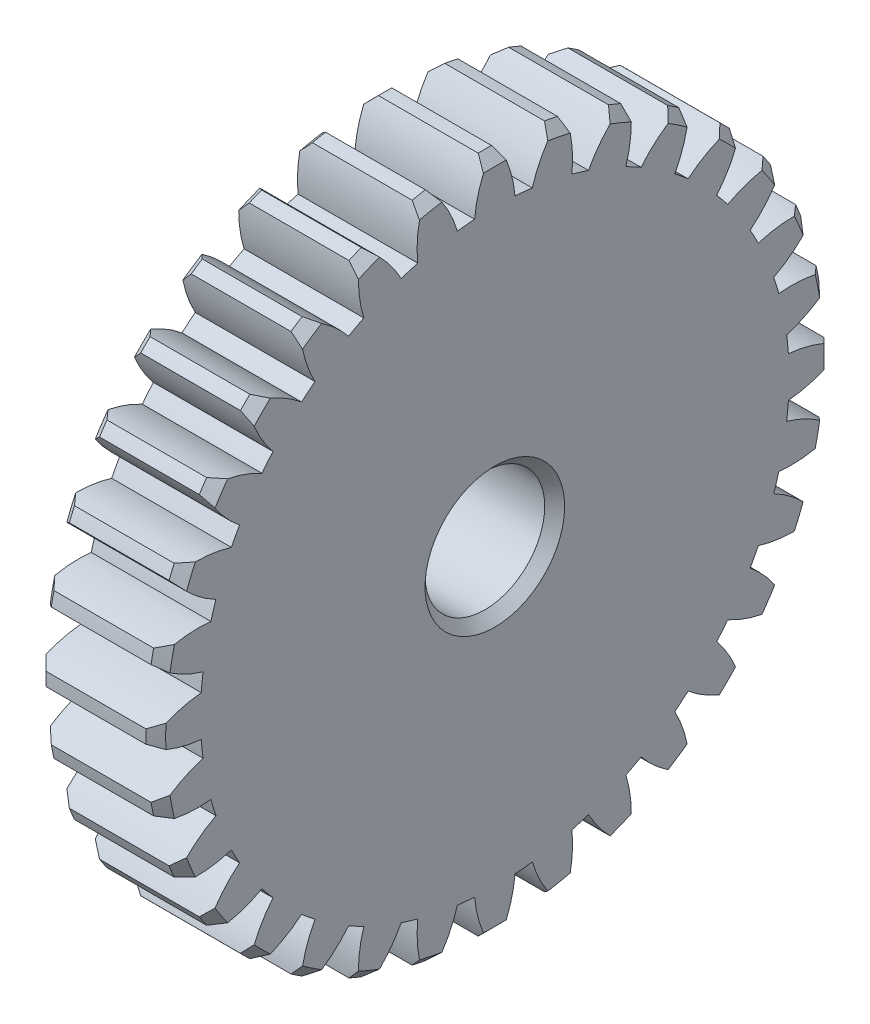
from build123d import *

# Parameters (mm, degrees)
SKETCH1_W                    = 6
SKETCH1_H                    = 17
CUT_EXTRUDE1_DEPTH           = 7
CUT_EXTRUDE2_DEPTH           = 7
CUT_EXTRUDE3_DEPTH           = 7
CUT_EXTRUDE4_DEPTH           = 7
CUT_EXTRUDE5_DEPTH           = 7
CUT_EXTRUDE6_DEPTH           = 7
CUT_EXTRUDE7_DEPTH           = 7
CUT_EXTRUDE8_DEPTH           = 7
CUT_EXTRUDE9_DEPTH           = 7
CUT_EXTRUDE10_DEPTH          = 7
CUT_EXTRUDE11_DEPTH          = 7
CUT_EXTRUDE12_DEPTH          = 7
CUT_EXTRUDE13_DEPTH          = 7
CUT_EXTRUDE14_DEPTH          = 7
CUT_EXTRUDE15_DEPTH          = 7
CUT_EXTRUDE16_DEPTH          = 7
CUT_EXTRUDE17_DEPTH          = 7
CUT_EXTRUDE18_DEPTH          = 7
CUT_EXTRUDE19_DEPTH          = 7
CUT_EXTRUDE20_DEPTH          = 7
CUT_EXTRUDE21_DEPTH          = 7
CUT_EXTRUDE22_DEPTH          = 7
CUT_EXTRUDE23_DEPTH          = 7
CUT_EXTRUDE24_DEPTH          = 7
CUT_EXTRUDE25_DEPTH          = 7
CUT_EXTRUDE26_DEPTH          = 7
CUT_EXTRUDE27_DEPTH          = 7
CUT_EXTRUDE28_DEPTH          = 7
CUT_EXTRUDE29_DEPTH          = 7
CUT_EXTRUDE30_DEPTH          = 7
CUT_EXTRUDE31_DEPTH          = 7
CUT_EXTRUDE32_DEPTH          = 7
F_6_0_6_DIAMETER_HOLE1_D     = 6
F_6_0_6_DIAMETER_HOLE1_DEPTH = 6
CHAMFER1_SIZE                = 0.5


with BuildPart() as part:
    # Sketch1 → Revolve1 (revolve)
    with BuildSketch(Plane.XY):
        with Locations((3, 8.5)):
            Rectangle(SKETCH1_W, SKETCH1_H)
    revolve(axis=Axis((0, 0, 0), (1, 0, 0)))

    # Sketch2 → Cut-Extrude1 (cut, through all)
    with BuildSketch(Plane(origin=(6, 0, 0), x_dir=(0, 0, -1), z_dir=(1, 0, 0))):
        with BuildLine():
            ThreePointArc((2.988536759, 16.735251658), (1.666291386, 16.918140353), (0.333772772, 16.996723088))
            ThreePointArc((0.333772772, 16.996723088), (0.787598479, 15.889968944), (1.012856819, 14.715183351))
            ThreePointArc((1.012856819, 14.715183351), (1.44575282, 14.678974718), (1.8773948, 14.630033792))
            ThreePointArc((1.8773948, 14.630033792), (2.327514163, 15.738300487), (2.988536759, 16.735251658))
        make_face()
    extrude(amount=-CUT_EXTRUDE1_DEPTH, mode=Mode.SUBTRACT)

    # Sketch3 → Cut-Extrude2 (cut, through all)
    with BuildSketch(Plane(origin=(6, 0, 0), x_dir=(0, 0, -1), z_dir=(1, 0, 0))):
        with BuildLine():
            ThreePointArc((6.195998498, 15.830653891), (4.934839513, 16.267985707), (3.643255602, 16.605019982))
            ThreePointArc((3.643255602, 16.605019982), (3.872444154, 15.430994806), (3.864184917, 14.234836667))
            ThreePointArc((3.864184917, 14.234836667), (4.28169899, 14.114869952), (4.695499189, 13.982660239))
            ThreePointArc((4.695499189, 13.982660239), (5.353181741, 14.981817969), (6.195998498, 15.830653891))
        make_face()
    extrude(amount=-CUT_EXTRUDE2_DEPTH, mode=Mode.SUBTRACT)

    # Sketch4 → Cut-Extrude3 (cut, through all)
    with BuildSketch(Plane(origin=(6, 0, 0), x_dir=(0, 0, -1), z_dir=(1, 0, 0))):
        with BuildLine():
            ThreePointArc((9.165351489, 14.317692973), (8.013744526, 14.992661494), (6.812730163, 15.575195271))
            ThreePointArc((6.812730163, 15.575195271), (6.808473971, 14.37901619), (6.567014557, 13.207453192))
            ThreePointArc((6.567014557, 13.207453192), (6.953101868, 13.008338649), (7.333158177, 12.797940895))
            ThreePointArc((7.333158177, 12.797940895), (8.173129547, 13.649592588), (9.165351489, 14.317692973))
        make_face()
    extrude(amount=-CUT_EXTRUDE3_DEPTH, mode=Mode.SUBTRACT)

    # Sketch5 → Cut-Extrude4 (cut, through all)
    with BuildSketch(Plane(origin=(6, 0, 0), x_dir=(0, 0, -1), z_dir=(1, 0, 0))):
        with BuildLine():
            ThreePointArc((11.782485163, 12.254511144), (10.784685831, 13.141177707), (9.720395324, 13.94682454))
            ThreePointArc((9.720395324, 13.94682454), (9.482857951, 12.774460047), (9.01747751, 11.672514697))
            ThreePointArc((9.01747751, 11.672514697), (9.357300941, 11.401904187), (9.689008009, 11.121403859))
            ThreePointArc((9.689008009, 11.121403859), (10.678988568, 11.792821019), (11.782485163, 12.254511144))
        make_face()
    extrude(amount=-CUT_EXTRUDE4_DEPTH, mode=Mode.SUBTRACT)

    # Sketch6 → Cut-Extrude5 (cut, through all)
    with BuildSketch(Plane(origin=(6, 0, 0), x_dir=(0, 0, -1), z_dir=(1, 0, 0))):
        with BuildLine():
            ThreePointArc((13.94682454, 9.720395324), (13.141177707, 10.784685831), (12.254511144, 11.782485163))
            ThreePointArc((12.254511144, 11.782485163), (11.792821019, 10.678988568), (11.121403859, 9.689008009))
            ThreePointArc((11.121403859, 9.689008009), (11.401904187, 9.357300941), (11.672514697, 9.01747751))
            ThreePointArc((11.672514697, 9.01747751), (12.774460047, 9.482857951), (13.94682454, 9.720395324))
        make_face()
    extrude(amount=-CUT_EXTRUDE5_DEPTH, mode=Mode.SUBTRACT)

    # Sketch7 → Cut-Extrude6 (cut, through all)
    with BuildSketch(Plane(origin=(6, 0, 0), x_dir=(0, 0, -1), z_dir=(1, 0, 0))):
        with BuildLine():
            ThreePointArc((15.575195271, 6.812730163), (14.992661494, 8.013744526), (14.317692973, 9.165351489))
            ThreePointArc((14.317692973, 9.165351489), (13.649592588, 8.173129547), (12.797940895, 7.333158177))
            ThreePointArc((12.797940895, 7.333158177), (13.008338649, 6.953101868), (13.207453192, 6.567014557))
            ThreePointArc((13.207453192, 6.567014557), (14.37901619, 6.808473971), (15.575195271, 6.812730163))
        make_face()
    extrude(amount=-CUT_EXTRUDE6_DEPTH, mode=Mode.SUBTRACT)

    # Sketch8 → Cut-Extrude7 (cut, through all)
    with BuildSketch(Plane(origin=(6, 0, 0), x_dir=(0, 0, -1), z_dir=(1, 0, 0))):
        with BuildLine():
            ThreePointArc((16.605019982, 3.643255602), (16.267985707, 4.934839513), (15.830653891, 6.195998498))
            ThreePointArc((15.830653891, 6.195998498), (14.981817969, 5.353181741), (13.982660239, 4.695499189))
            ThreePointArc((13.982660239, 4.695499189), (14.114869952, 4.28169899), (14.234836667, 3.864184917))
            ThreePointArc((14.234836667, 3.864184917), (15.430994806, 3.872444154), (16.605019982, 3.643255602))
        make_face()
    extrude(amount=-CUT_EXTRUDE7_DEPTH, mode=Mode.SUBTRACT)

    # Sketch9 → Cut-Extrude8 (cut, through all)
    with BuildSketch(Plane(origin=(6, 0, 0), x_dir=(0, 0, -1), z_dir=(1, 0, 0))):
        with BuildLine():
            ThreePointArc((16.996723088, 0.333772772), (16.918140353, 1.666291386), (16.735251658, 2.988536759))
            ThreePointArc((16.735251658, 2.988536759), (15.738300487, 2.327514163), (14.630033792, 1.8773948))
            ThreePointArc((14.630033792, 1.8773948), (14.678974718, 1.44575282), (14.715183351, 1.012856819))
            ThreePointArc((14.715183351, 1.012856819), (15.889968944, 0.787598479), (16.996723088, 0.333772772))
        make_face()
    extrude(amount=-CUT_EXTRUDE8_DEPTH, mode=Mode.SUBTRACT)

    # Sketch10 → Cut-Extrude9 (cut, through all)
    with BuildSketch(Plane(origin=(6, 0, 0), x_dir=(0, 0, -1), z_dir=(1, 0, 0))):
        with BuildLine():
            ThreePointArc((16.735251658, -2.988536759), (16.918140353, -1.666291386), (16.996723088, -0.333772772))
            ThreePointArc((16.996723088, -0.333772772), (15.889968944, -0.787598479), (14.715183351, -1.012856819))
            ThreePointArc((14.715183351, -1.012856819), (14.678974718, -1.44575282), (14.630033792, -1.8773948))
            ThreePointArc((14.630033792, -1.8773948), (15.738300487, -2.327514163), (16.735251658, -2.988536759))
        make_face()
    extrude(amount=-CUT_EXTRUDE9_DEPTH, mode=Mode.SUBTRACT)

    # Sketch11 → Cut-Extrude10 (cut, through all)
    with BuildSketch(Plane(origin=(6, 0, 0), x_dir=(0, 0, -1), z_dir=(1, 0, 0))):
        with BuildLine():
            ThreePointArc((15.830653891, -6.195998498), (16.267985707, -4.934839513), (16.605019982, -3.643255602))
            ThreePointArc((16.605019982, -3.643255602), (15.430994806, -3.872444154), (14.234836667, -3.864184917))
            ThreePointArc((14.234836667, -3.864184917), (14.114869952, -4.28169899), (13.982660239, -4.695499189))
            ThreePointArc((13.982660239, -4.695499189), (14.981817969, -5.353181741), (15.830653891, -6.195998498))
        make_face()
    extrude(amount=-CUT_EXTRUDE10_DEPTH, mode=Mode.SUBTRACT)

    # Sketch12 → Cut-Extrude11 (cut, through all)
    with BuildSketch(Plane(origin=(6, 0, 0), x_dir=(0, 0, -1), z_dir=(1, 0, 0))):
        with BuildLine():
            ThreePointArc((14.317692973, -9.165351489), (14.992661494, -8.013744526), (15.575195271, -6.812730163))
            ThreePointArc((15.575195271, -6.812730163), (14.37901619, -6.808473971), (13.207453192, -6.567014557))
            ThreePointArc((13.207453192, -6.567014557), (13.008338649, -6.953101868), (12.797940895, -7.333158177))
            ThreePointArc((12.797940895, -7.333158177), (13.649592588, -8.173129547), (14.317692973, -9.165351489))
        make_face()
    extrude(amount=-CUT_EXTRUDE11_DEPTH, mode=Mode.SUBTRACT)

    # Sketch13 → Cut-Extrude12 (cut, through all)
    with BuildSketch(Plane(origin=(6, 0, 0), x_dir=(0, 0, -1), z_dir=(1, 0, 0))):
        with BuildLine():
            ThreePointArc((12.254511144, -11.782485163), (13.141177707, -10.784685831), (13.94682454, -9.720395324))
            ThreePointArc((13.94682454, -9.720395324), (12.774460047, -9.482857951), (11.672514697, -9.01747751))
            ThreePointArc((11.672514697, -9.01747751), (11.401904187, -9.357300941), (11.121403859, -9.689008009))
            ThreePointArc((11.121403859, -9.689008009), (11.792821019, -10.678988568), (12.254511144, -11.782485163))
        make_face()
    extrude(amount=-CUT_EXTRUDE12_DEPTH, mode=Mode.SUBTRACT)

    # Sketch14 → Cut-Extrude13 (cut, through all)
    with BuildSketch(Plane(origin=(6, 0, 0), x_dir=(0, 0, -1), z_dir=(1, 0, 0))):
        with BuildLine():
            ThreePointArc((9.720395324, -13.94682454), (10.784685831, -13.141177707), (11.782485163, -12.254511144))
            ThreePointArc((11.782485163, -12.254511144), (10.678988568, -11.792821019), (9.689008009, -11.121403859))
            ThreePointArc((9.689008009, -11.121403859), (9.357300941, -11.401904187), (9.01747751, -11.672514697))
            ThreePointArc((9.01747751, -11.672514697), (9.482857951, -12.774460047), (9.720395324, -13.94682454))
        make_face()
    extrude(amount=-CUT_EXTRUDE13_DEPTH, mode=Mode.SUBTRACT)

    # Sketch15 → Cut-Extrude14 (cut, through all)
    with BuildSketch(Plane(origin=(6, 0, 0), x_dir=(0, 0, -1), z_dir=(1, 0, 0))):
        with BuildLine():
            ThreePointArc((6.812730163, -15.575195271), (8.013744526, -14.992661494), (9.165351489, -14.317692973))
            ThreePointArc((9.165351489, -14.317692973), (8.173129547, -13.649592588), (7.333158177, -12.797940895))
            ThreePointArc((7.333158177, -12.797940895), (6.953101868, -13.008338649), (6.567014557, -13.207453192))
            ThreePointArc((6.567014557, -13.207453192), (6.808473971, -14.37901619), (6.812730163, -15.575195271))
        make_face()
    extrude(amount=-CUT_EXTRUDE14_DEPTH, mode=Mode.SUBTRACT)

    # Sketch16 → Cut-Extrude15 (cut, through all)
    with BuildSketch(Plane(origin=(6, 0, 0), x_dir=(0, 0, -1), z_dir=(1, 0, 0))):
        with BuildLine():
            ThreePointArc((3.643255602, -16.605019982), (4.934839513, -16.267985707), (6.195998498, -15.830653891))
            ThreePointArc((6.195998498, -15.830653891), (5.353181741, -14.981817969), (4.695499189, -13.982660239))
            ThreePointArc((4.695499189, -13.982660239), (4.28169899, -14.114869952), (3.864184917, -14.234836667))
            ThreePointArc((3.864184917, -14.234836667), (3.872444154, -15.430994806), (3.643255602, -16.605019982))
        make_face()
    extrude(amount=-CUT_EXTRUDE15_DEPTH, mode=Mode.SUBTRACT)

    # Sketch17 → Cut-Extrude16 (cut, through all)
    with BuildSketch(Plane(origin=(6, 0, 0), x_dir=(0, 0, -1), z_dir=(1, 0, 0))):
        with BuildLine():
            ThreePointArc((0.333772772, -16.996723088), (1.666291386, -16.918140353), (2.988536759, -16.735251658))
            ThreePointArc((2.988536759, -16.735251658), (2.327514163, -15.738300487), (1.8773948, -14.630033792))
            ThreePointArc((1.8773948, -14.630033792), (1.44575282, -14.678974718), (1.012856819, -14.715183351))
            ThreePointArc((1.012856819, -14.715183351), (0.787598479, -15.889968944), (0.333772772, -16.996723088))
        make_face()
    extrude(amount=-CUT_EXTRUDE16_DEPTH, mode=Mode.SUBTRACT)

    # Sketch18 → Cut-Extrude17 (cut, through all)
    with BuildSketch(Plane(origin=(6, 0, 0), x_dir=(0, 0, -1), z_dir=(1, 0, 0))):
        with BuildLine():
            ThreePointArc((-2.988536759, -16.735251658), (-1.666291386, -16.918140353), (-0.333772772, -16.996723088))
            ThreePointArc((-0.333772772, -16.996723088), (-0.787598479, -15.889968944), (-1.012856819, -14.715183351))
            ThreePointArc((-1.012856819, -14.715183351), (-1.44575282, -14.678974718), (-1.8773948, -14.630033792))
            ThreePointArc((-1.8773948, -14.630033792), (-2.327514163, -15.738300487), (-2.988536759, -16.735251658))
        make_face()
    extrude(amount=-CUT_EXTRUDE17_DEPTH, mode=Mode.SUBTRACT)

    # Sketch19 → Cut-Extrude18 (cut, through all)
    with BuildSketch(Plane(origin=(6, 0, 0), x_dir=(0, 0, -1), z_dir=(1, 0, 0))):
        with BuildLine():
            ThreePointArc((-6.195998498, -15.830653891), (-4.934839513, -16.267985707), (-3.643255602, -16.605019982))
            ThreePointArc((-3.643255602, -16.605019982), (-3.872444154, -15.430994806), (-3.864184917, -14.234836667))
            ThreePointArc((-3.864184917, -14.234836667), (-4.28169899, -14.114869952), (-4.695499189, -13.982660239))
            ThreePointArc((-4.695499189, -13.982660239), (-5.353181741, -14.981817969), (-6.195998498, -15.830653891))
        make_face()
    extrude(amount=-CUT_EXTRUDE18_DEPTH, mode=Mode.SUBTRACT)

    # Sketch20 → Cut-Extrude19 (cut, through all)
    with BuildSketch(Plane(origin=(6, 0, 0), x_dir=(0, 0, -1), z_dir=(1, 0, 0))):
        with BuildLine():
            ThreePointArc((-9.165351489, -14.317692973), (-8.013744526, -14.992661494), (-6.812730163, -15.575195271))
            ThreePointArc((-6.812730163, -15.575195271), (-6.808473971, -14.37901619), (-6.567014557, -13.207453192))
            ThreePointArc((-6.567014557, -13.207453192), (-6.953101868, -13.008338649), (-7.333158177, -12.797940895))
            ThreePointArc((-7.333158177, -12.797940895), (-8.173129547, -13.649592588), (-9.165351489, -14.317692973))
        make_face()
    extrude(amount=-CUT_EXTRUDE19_DEPTH, mode=Mode.SUBTRACT)

    # Sketch21 → Cut-Extrude20 (cut, through all)
    with BuildSketch(Plane(origin=(6, 0, 0), x_dir=(0, 0, -1), z_dir=(1, 0, 0))):
        with BuildLine():
            ThreePointArc((-11.782485163, -12.254511144), (-10.784685831, -13.141177707), (-9.720395324, -13.94682454))
            ThreePointArc((-9.720395324, -13.94682454), (-9.482857951, -12.774460047), (-9.01747751, -11.672514697))
            ThreePointArc((-9.01747751, -11.672514697), (-9.357300941, -11.401904187), (-9.689008009, -11.121403859))
            ThreePointArc((-9.689008009, -11.121403859), (-10.678988568, -11.792821019), (-11.782485163, -12.254511144))
        make_face()
    extrude(amount=-CUT_EXTRUDE20_DEPTH, mode=Mode.SUBTRACT)

    # Sketch22 → Cut-Extrude21 (cut, through all)
    with BuildSketch(Plane(origin=(6, 0, 0), x_dir=(0, 0, -1), z_dir=(1, 0, 0))):
        with BuildLine():
            ThreePointArc((-13.94682454, -9.720395324), (-13.141177707, -10.784685831), (-12.254511144, -11.782485163))
            ThreePointArc((-12.254511144, -11.782485163), (-11.792821019, -10.678988568), (-11.121403859, -9.689008009))
            ThreePointArc((-11.121403859, -9.689008009), (-11.401904187, -9.357300941), (-11.672514697, -9.01747751))
            ThreePointArc((-11.672514697, -9.01747751), (-12.774460047, -9.482857951), (-13.94682454, -9.720395324))
        make_face()
    extrude(amount=-CUT_EXTRUDE21_DEPTH, mode=Mode.SUBTRACT)

    # Sketch23 → Cut-Extrude22 (cut, through all)
    with BuildSketch(Plane(origin=(6, 0, 0), x_dir=(0, 0, -1), z_dir=(1, 0, 0))):
        with BuildLine():
            ThreePointArc((-15.575195271, -6.812730163), (-14.992661494, -8.013744526), (-14.317692973, -9.165351489))
            ThreePointArc((-14.317692973, -9.165351489), (-13.649592588, -8.173129547), (-12.797940895, -7.333158177))
            ThreePointArc((-12.797940895, -7.333158177), (-13.008338649, -6.953101868), (-13.207453192, -6.567014557))
            ThreePointArc((-13.207453192, -6.567014557), (-14.37901619, -6.808473971), (-15.575195271, -6.812730163))
        make_face()
    extrude(amount=-CUT_EXTRUDE22_DEPTH, mode=Mode.SUBTRACT)

    # Sketch24 → Cut-Extrude23 (cut, through all)
    with BuildSketch(Plane(origin=(6, 0, 0), x_dir=(0, 0, -1), z_dir=(1, 0, 0))):
        with BuildLine():
            ThreePointArc((-16.605019982, -3.643255602), (-16.267985707, -4.934839513), (-15.830653891, -6.195998498))
            ThreePointArc((-15.830653891, -6.195998498), (-14.981817969, -5.353181741), (-13.982660239, -4.695499189))
            ThreePointArc((-13.982660239, -4.695499189), (-14.114869952, -4.28169899), (-14.234836667, -3.864184917))
            ThreePointArc((-14.234836667, -3.864184917), (-15.430994806, -3.872444154), (-16.605019982, -3.643255602))
        make_face()
    extrude(amount=-CUT_EXTRUDE23_DEPTH, mode=Mode.SUBTRACT)

    # Sketch25 → Cut-Extrude24 (cut, through all)
    with BuildSketch(Plane(origin=(6, 0, 0), x_dir=(0, 0, -1), z_dir=(1, 0, 0))):
        with BuildLine():
            ThreePointArc((-16.996723088, -0.333772772), (-16.918140353, -1.666291386), (-16.735251658, -2.988536759))
            ThreePointArc((-16.735251658, -2.988536759), (-15.738300487, -2.327514163), (-14.630033792, -1.8773948))
            ThreePointArc((-14.630033792, -1.8773948), (-14.678974718, -1.44575282), (-14.715183351, -1.012856819))
            ThreePointArc((-14.715183351, -1.012856819), (-15.889968944, -0.787598479), (-16.996723088, -0.333772772))
        make_face()
    extrude(amount=-CUT_EXTRUDE24_DEPTH, mode=Mode.SUBTRACT)

    # Sketch26 → Cut-Extrude25 (cut, through all)
    with BuildSketch(Plane(origin=(6, 0, 0), x_dir=(0, 0, -1), z_dir=(1, 0, 0))):
        with BuildLine():
            ThreePointArc((-16.735251658, 2.988536759), (-16.918140353, 1.666291386), (-16.996723088, 0.333772772))
            ThreePointArc((-16.996723088, 0.333772772), (-15.889968944, 0.787598479), (-14.715183351, 1.012856819))
            ThreePointArc((-14.715183351, 1.012856819), (-14.678974718, 1.44575282), (-14.630033792, 1.8773948))
            ThreePointArc((-14.630033792, 1.8773948), (-15.738300487, 2.327514163), (-16.735251658, 2.988536759))
        make_face()
    extrude(amount=-CUT_EXTRUDE25_DEPTH, mode=Mode.SUBTRACT)

    # Sketch27 → Cut-Extrude26 (cut, through all)
    with BuildSketch(Plane(origin=(6, 0, 0), x_dir=(0, 0, -1), z_dir=(1, 0, 0))):
        with BuildLine():
            ThreePointArc((-15.830653891, 6.195998498), (-16.267985707, 4.934839513), (-16.605019982, 3.643255602))
            ThreePointArc((-16.605019982, 3.643255602), (-15.430994806, 3.872444154), (-14.234836667, 3.864184917))
            ThreePointArc((-14.234836667, 3.864184917), (-14.114869952, 4.28169899), (-13.982660239, 4.695499189))
            ThreePointArc((-13.982660239, 4.695499189), (-14.981817969, 5.353181741), (-15.830653891, 6.195998498))
        make_face()
    extrude(amount=-CUT_EXTRUDE26_DEPTH, mode=Mode.SUBTRACT)

    # Sketch28 → Cut-Extrude27 (cut, through all)
    with BuildSketch(Plane(origin=(6, 0, 0), x_dir=(0, 0, -1), z_dir=(1, 0, 0))):
        with BuildLine():
            ThreePointArc((-14.317692973, 9.165351489), (-14.992661494, 8.013744526), (-15.575195271, 6.812730163))
            ThreePointArc((-15.575195271, 6.812730163), (-14.37901619, 6.808473971), (-13.207453192, 6.567014557))
            ThreePointArc((-13.207453192, 6.567014557), (-13.008338649, 6.953101868), (-12.797940895, 7.333158177))
            ThreePointArc((-12.797940895, 7.333158177), (-13.649592588, 8.173129547), (-14.317692973, 9.165351489))
        make_face()
    extrude(amount=-CUT_EXTRUDE27_DEPTH, mode=Mode.SUBTRACT)

    # Sketch29 → Cut-Extrude28 (cut, through all)
    with BuildSketch(Plane(origin=(6, 0, 0), x_dir=(0, 0, -1), z_dir=(1, 0, 0))):
        with BuildLine():
            ThreePointArc((-12.254511144, 11.782485163), (-13.141177707, 10.784685831), (-13.94682454, 9.720395324))
            ThreePointArc((-13.94682454, 9.720395324), (-12.774460047, 9.482857951), (-11.672514697, 9.01747751))
            ThreePointArc((-11.672514697, 9.01747751), (-11.401904187, 9.357300941), (-11.121403859, 9.689008009))
            ThreePointArc((-11.121403859, 9.689008009), (-11.792821019, 10.678988568), (-12.254511144, 11.782485163))
        make_face()
    extrude(amount=-CUT_EXTRUDE28_DEPTH, mode=Mode.SUBTRACT)

    # Sketch30 → Cut-Extrude29 (cut, through all)
    with BuildSketch(Plane(origin=(6, 0, 0), x_dir=(0, 0, -1), z_dir=(1, 0, 0))):
        with BuildLine():
            ThreePointArc((-9.720395324, 13.94682454), (-10.784685831, 13.141177707), (-11.782485163, 12.254511144))
            ThreePointArc((-11.782485163, 12.254511144), (-10.678988568, 11.792821019), (-9.689008009, 11.121403859))
            ThreePointArc((-9.689008009, 11.121403859), (-9.357300941, 11.401904187), (-9.01747751, 11.672514697))
            ThreePointArc((-9.01747751, 11.672514697), (-9.482857951, 12.774460047), (-9.720395324, 13.94682454))
        make_face()
    extrude(amount=-CUT_EXTRUDE29_DEPTH, mode=Mode.SUBTRACT)

    # Sketch31 → Cut-Extrude30 (cut, through all)
    with BuildSketch(Plane(origin=(6, 0, 0), x_dir=(0, 0, -1), z_dir=(1, 0, 0))):
        with BuildLine():
            ThreePointArc((-6.812730163, 15.575195271), (-8.013744526, 14.992661494), (-9.165351489, 14.317692973))
            ThreePointArc((-9.165351489, 14.317692973), (-8.173129547, 13.649592588), (-7.333158177, 12.797940895))
            ThreePointArc((-7.333158177, 12.797940895), (-6.953101868, 13.008338649), (-6.567014557, 13.207453192))
            ThreePointArc((-6.567014557, 13.207453192), (-6.808473971, 14.37901619), (-6.812730163, 15.575195271))
        make_face()
    extrude(amount=-CUT_EXTRUDE30_DEPTH, mode=Mode.SUBTRACT)

    # Sketch32 → Cut-Extrude31 (cut, through all)
    with BuildSketch(Plane(origin=(6, 0, 0), x_dir=(0, 0, -1), z_dir=(1, 0, 0))):
        with BuildLine():
            ThreePointArc((-3.643255602, 16.605019982), (-4.934839513, 16.267985707), (-6.195998498, 15.830653891))
            ThreePointArc((-6.195998498, 15.830653891), (-5.353181741, 14.981817969), (-4.695499189, 13.982660239))
            ThreePointArc((-4.695499189, 13.982660239), (-4.28169899, 14.114869952), (-3.864184917, 14.234836667))
            ThreePointArc((-3.864184917, 14.234836667), (-3.872444154, 15.430994806), (-3.643255602, 16.605019982))
        make_face()
    extrude(amount=-CUT_EXTRUDE31_DEPTH, mode=Mode.SUBTRACT)

    # Sketch33 → Cut-Extrude32 (cut, through all)
    with BuildSketch(Plane(origin=(6, 0, 0), x_dir=(0, 0, -1), z_dir=(1, 0, 0))):
        with BuildLine():
            ThreePointArc((-0.333772772, 16.996723088), (-1.666291386, 16.918140353), (-2.988536759, 16.735251658))
            ThreePointArc((-2.988536759, 16.735251658), (-2.327514163, 15.738300487), (-1.8773948, 14.630033792))
            ThreePointArc((-1.8773948, 14.630033792), (-1.44575282, 14.678974718), (-1.012856819, 14.715183351))
            ThreePointArc((-1.012856819, 14.715183351), (-0.787598479, 15.889968944), (-0.333772772, 16.996723088))
        make_face()
    extrude(amount=-CUT_EXTRUDE32_DEPTH, mode=Mode.SUBTRACT)

    # Ø6.0 (6) Diameter Hole1
    with Locations(Plane.ZY):
        with Locations((0, 0)):
            Hole(F_6_0_6_DIAMETER_HOLE1_D / 2, depth=F_6_0_6_DIAMETER_HOLE1_DEPTH)

    # Chamfer1
    chamfer1_edges = [part.edges().sort_by_distance(p)[0] for p in [
        (6, 17, 0),
        (6, 6.50561835, -15.705952053),
        (0, 6.50561835, -15.705952053),
        (0, 17, 0),
        (6, 3.316535474, -16.673349767),
        (0, 3.316535474, -16.673349767),
        (6, 0, -17),
        (0, 0, -17),
        (6, -3.316535474, -16.673349767),
        (0, -3.316535474, -16.673349767),
        (6, -6.50561835, -15.705952053),
        (0, -6.50561835, -15.705952053),
        (6, -9.444693961, -14.134983409),
        (0, -9.444693961, -14.134983409),
        (6, -12.02081528, -12.02081528),
        (0, -12.02081528, -12.02081528),
        (6, -14.134983409, -9.444693961),
        (0, -14.134983409, -9.444693961),
        (6, 16.673349767, -3.316535474),
        (6, -15.705952053, -6.50561835),
        (0, -15.705952053, -6.50561835),
        (0, 16.673349767, -3.316535474),
        (6, -16.673349767, -3.316535474),
        (0, -16.673349767, -3.316535474),
        (6, -17, 0),
        (0, -17, 0),
        (6, -16.673349767, 3.316535474),
        (0, -16.673349767, 3.316535474),
        (6, -15.705952053, 6.50561835),
        (0, -15.705952053, 6.50561835),
        (6, -14.134983409, 9.444693961),
        (0, -14.134983409, 9.444693961),
        (6, -12.02081528, 12.02081528),
        (0, -12.02081528, 12.02081528),
        (6, -9.444693961, 14.134983409),
        (0, -9.444693961, 14.134983409),
        (6, -6.50561835, 15.705952053),
        (0, -6.50561835, 15.705952053),
        (6, -3.316535474, 16.673349767),
        (0, -3.316535474, 16.673349767),
        (6, 0, 17),
        (0, 0, 17),
        (6, 15.705952053, -6.50561835),
        (6, 3.316535474, 16.673349767),
        (0, 3.316535474, 16.673349767),
        (0, 15.705952053, -6.50561835),
        (6, 6.50561835, 15.705952053),
        (0, 6.50561835, 15.705952053),
        (6, 9.444693961, 14.134983409),
        (0, 9.444693961, 14.134983409),
        (6, 12.02081528, 12.02081528),
        (0, 12.02081528, 12.02081528),
        (6, 14.134983409, 9.444693961),
        (0, 14.134983409, 9.444693961),
        (6, 15.705952053, 6.50561835),
        (0, 15.705952053, 6.50561835),
        (6, 16.673349767, 3.316535474),
        (0, 16.673349767, 3.316535474),
        (0, 0, 3),
        (6, 0, 3),
        (6, 14.134983409, -9.444693961),
        (0, 14.134983409, -9.444693961),
        (6, 12.02081528, -12.02081528),
        (0, 12.02081528, -12.02081528),
        (6, 9.444693961, -14.134983409),
        (0, 9.444693961, -14.134983409),
    ]]
    chamfer(chamfer1_edges, length=CHAMFER1_SIZE)


solid = part.part
